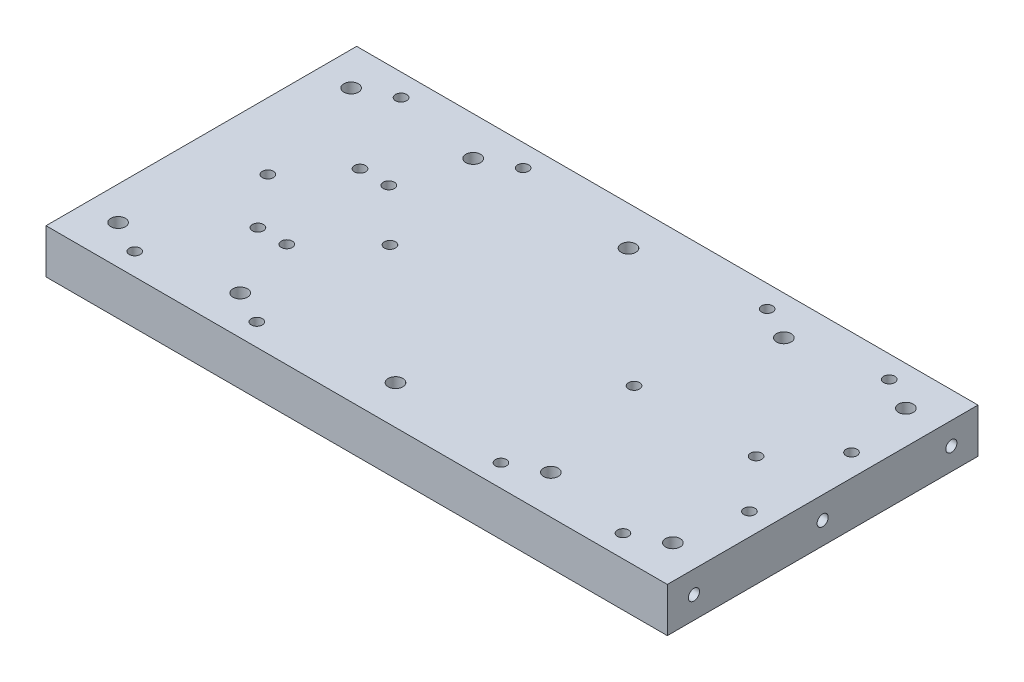
from build123d import *

# Parameters (mm, degrees)
SKETCH1_W                                            = 280
SKETCH1_H                                            = 140
EXTRUDE1_DEPTH                                       = 20
M6_TAPPED_HOLE1_D                                    = 5
M6_TAPPED_HOLE2_D                                    = 5
M6_TAPPED_HOLE3_D                                    = 5
M6_TAPPED_HOLE3_DEPTH                                = 25
M6_TAPPED_HOLE3_TIP                                  = 1.502151548
CBORE_FOR_M6_HEX_SOCKET_THIN_HEAD_CAP_SC_D           = 6.6
CBORE_FOR_M6_HEX_SOCKET_THIN_HEAD_CAP_SC_CBORE_D     = 11
CBORE_FOR_M6_HEX_SOCKET_THIN_HEAD_CAP_SC_CBORE_DEPTH = 4.6
M6_TAPPED_HOLE4_D                                    = 5
M6_TAPPED_HOLE4_DEPTH                                = 25
M6_TAPPED_HOLE4_TIP                                  = 1.502151548


with BuildPart() as part:
    # Sketch1 → Extrude1 (new body)
    with BuildSketch(Plane(origin=(0, 0, 0), x_dir=(1, 0, 0), z_dir=(0, 1, 0))):
        Rectangle(SKETCH1_W, SKETCH1_H)
    extrude(amount=EXTRUDE1_DEPTH)

    # M6 Tapped Hole1 (through all)
    with Locations(Plane(origin=(0, 0, 0), x_dir=(-1, 0, 0), z_dir=(0, -1, 0))):
        with Locations((-110, 60), (-55, 60), (-110, 0), (-55, 0), (-110, -60), (-55, -60), (55, 60), (110, 60), (110, 0), (55, 0), (110, -60), (55, -60)):
            Hole(M6_TAPPED_HOLE1_D / 2)

    # M6 Tapped Hole2 (through all)
    with Locations(Plane(origin=(0, 20, 0), x_dir=(1, 0, 0), z_dir=(0, 1, 0))):
        with Locations((-91.5, 23), (-78.5, 23), (-91.5, -23), (-78.5, -23), (130, 23), (130, -23)):
            Hole(M6_TAPPED_HOLE2_D / 2)

    # M6 Tapped Hole3
    with Locations(Plane(origin=(140, 0, 0), x_dir=(0, 0, -1), z_dir=(1, 0, 0))):
        with Locations((-58, 10), (0, 10), (58, 10)):
            Hole(M6_TAPPED_HOLE3_D / 2, depth=M6_TAPPED_HOLE3_DEPTH)
            with Locations((0, 0, -(M6_TAPPED_HOLE3_DEPTH + M6_TAPPED_HOLE3_TIP / 2))):  # 118° drill point
                Cone(0, M6_TAPPED_HOLE3_D / 2, M6_TAPPED_HOLE3_TIP, mode=Mode.SUBTRACT)

    # CBORE for M6 Hex Socket Thin Head Cap Screw1 (through all)
    with Locations(Plane(origin=(0, 0, 0), x_dir=(-1, 0, 0), z_dir=(0, -1, 0))):
        with Locations((-125, 52.5), (-70, 52.5), (0, 52.5), (0, -52.5), (-70, -52.5), (-125, -52.5), (125, -52.5), (70, -52.5), (70, 52.5), (125, 52.5)):
            CounterBoreHole(CBORE_FOR_M6_HEX_SOCKET_THIN_HEAD_CAP_SC_D / 2, CBORE_FOR_M6_HEX_SOCKET_THIN_HEAD_CAP_SC_CBORE_D / 2, CBORE_FOR_M6_HEX_SOCKET_THIN_HEAD_CAP_SC_CBORE_DEPTH)

    # M6 Tapped Hole4
    with Locations(Plane.ZY.offset(140)):
        with Locations((58, 10), (0, 10), (-58, 10)):
            Hole(M6_TAPPED_HOLE4_D / 2, depth=M6_TAPPED_HOLE4_DEPTH)
            with Locations((0, 0, -(M6_TAPPED_HOLE4_DEPTH + M6_TAPPED_HOLE4_TIP / 2))):  # 118° drill point
                Cone(0, M6_TAPPED_HOLE4_D / 2, M6_TAPPED_HOLE4_TIP, mode=Mode.SUBTRACT)


solid = part.part
